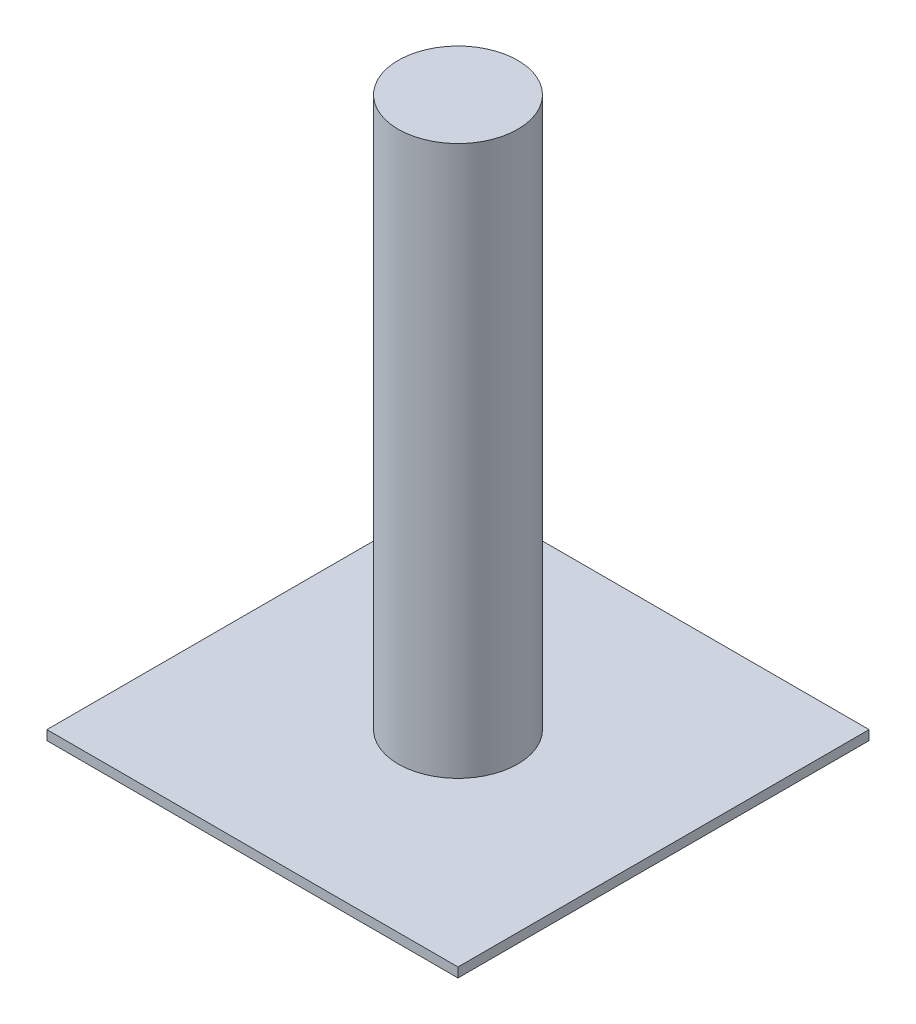
from build123d import *

# Parameters (mm, degrees)
SKETCH1_W           = 86
SKETCH1_H           = 86
BOSS_EXTRUDE1_DEPTH = 2
SKETCH2_R           = 12.5
BOSS_EXTRUDE2_DEPTH = 115


with BuildPart() as part:
    # Sketch1 → Boss-Extrude1 (new body)
    with BuildSketch(Plane(origin=(0, 0, 0), x_dir=(1, 0, 0), z_dir=(0, 1, 0))):
        Rectangle(SKETCH1_W, SKETCH1_H)
    extrude(amount=BOSS_EXTRUDE1_DEPTH)

    # Sketch2 → Boss-Extrude2 (add)
    with BuildSketch(Plane(origin=(0, 2, 0), x_dir=(1, 0, 0), z_dir=(0, 1, 0))):
        Circle(SKETCH2_R)
    extrude(amount=BOSS_EXTRUDE2_DEPTH)


solid = part.part
